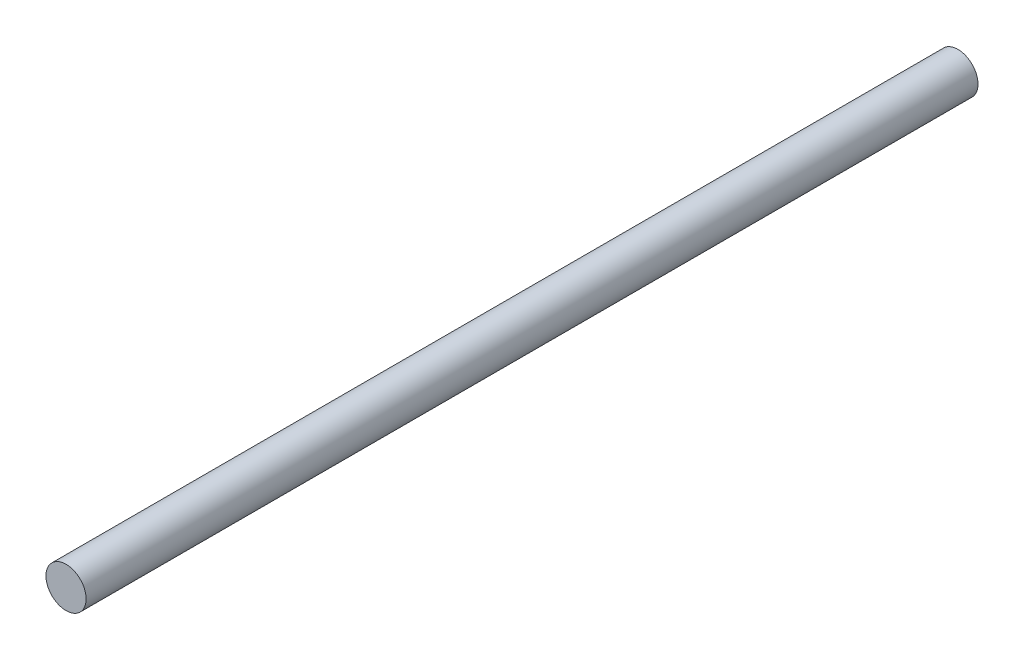
from build123d import *

# Parameters (mm, degrees)
SKETCH1_R           = 2.5
BOSS_EXTRUDE1_DEPTH = 111


with BuildPart() as part:
    # Sketch1 → Boss-Extrude1 (new body)
    with BuildSketch(Plane.XY):
        Circle(SKETCH1_R)
    extrude(amount=BOSS_EXTRUDE1_DEPTH)


solid = part.part
